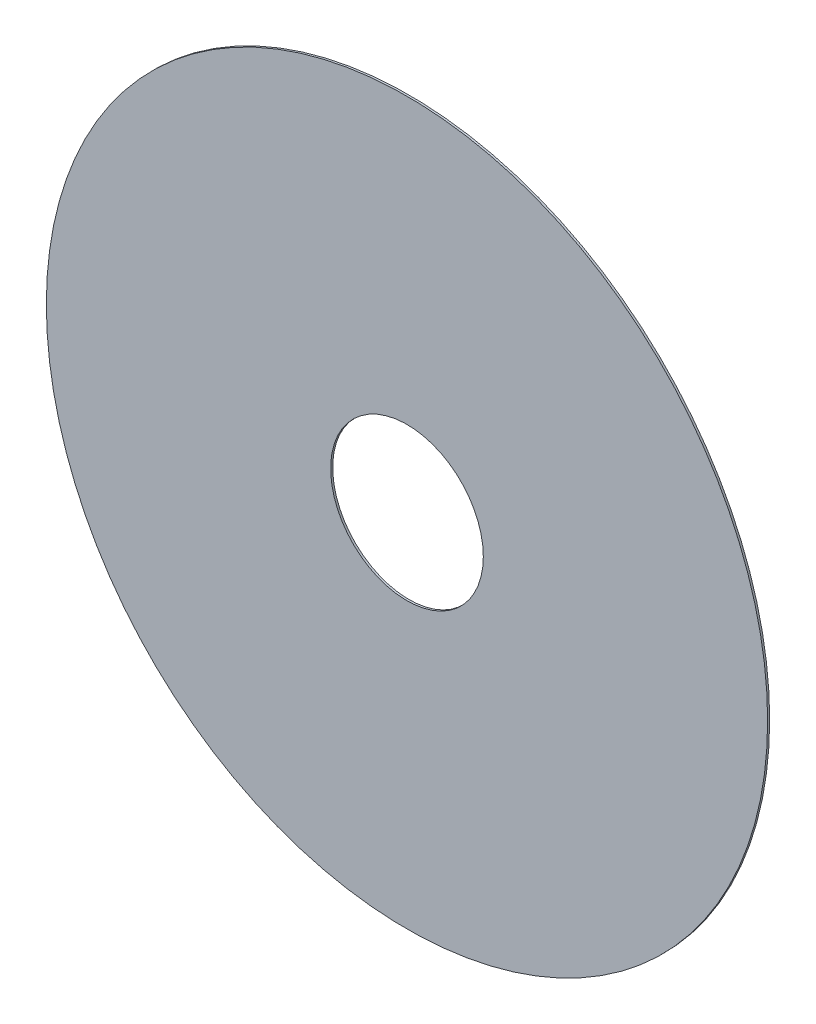
from build123d import *

# Parameters (mm, degrees)
SKETCH1_R           = 18
SKETCH1_R_2         = 3.81
BOSS_EXTRUDE1_DEPTH = 0.1016


with BuildPart() as part:
    # Sketch1 → Boss-Extrude1 (new body)
    with BuildSketch(Plane.XY):
        Circle(SKETCH1_R)
        Circle(SKETCH1_R_2, mode=Mode.SUBTRACT)
    extrude(amount=BOSS_EXTRUDE1_DEPTH)


solid = part.part
